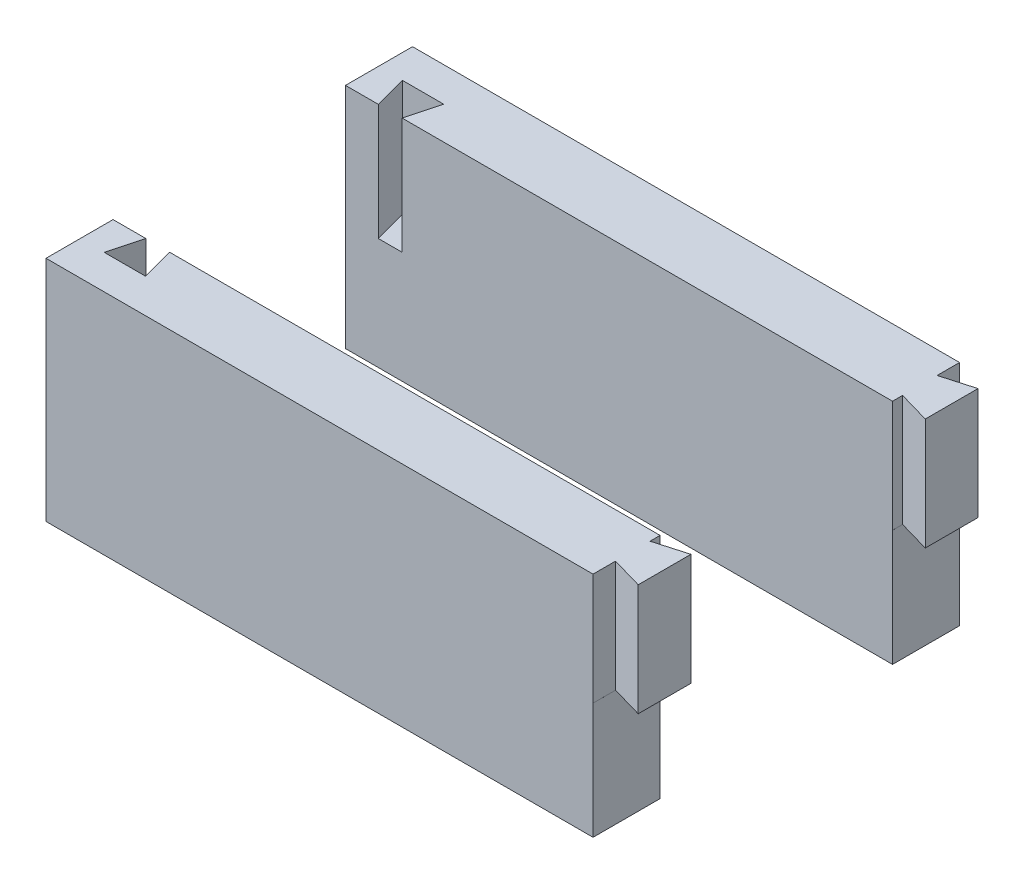
from build123d import *

# Parameters (mm, degrees)
SKETCH1_W               = 129.5
SKETCH1_H               = 51
BOSS_EXTRUDE1_DEPTH     = 15
CUT_EXTRUDE2_DEPTH      = 1
CUT_EXTRUDE2_DEPTH_BACK = 26
CUT_EXTRUDE4_DEPTH      = 25
SKETCH7_W               = 7.11
SKETCH7_H               = 15
CUT_EXTRUDE5_DEPTH      = 26


with BuildPart() as part:
    # Sketch1 → Boss-Extrude1 (new body)
    with BuildSketch(Plane.XY):
        with Locations((3.813380282, 3.112676056)):
            Rectangle(SKETCH1_W, SKETCH1_H)
    extrude(amount=BOSS_EXTRUDE1_DEPTH)

    # Sketch3 → Cut-Extrude2 (cut, two sides)
    with BuildSketch(Plane(origin=(0, 28.612676056, 0), x_dir=(1, 0, 0), z_dir=(0, 1, 0))) as cut_extrude2_sk:
        Polygon((-331.668282544, 0), (-60.936619718, 0), (-53.586619718, 0), (-55.553644461, -7.34103628), (-46.319594976, -7.34103628), (-48.286619718, 0), (-118.35713017, 261.506705118), (-537.936404333, 603.757732463), (-751.247556708, 342.251027345), align=None)
    extrude(amount=CUT_EXTRUDE2_DEPTH, mode=Mode.SUBTRACT)
    extrude(cut_extrude2_sk.sketch, amount=-CUT_EXTRUDE2_DEPTH_BACK, mode=Mode.SUBTRACT)

    # Sketch5 → Cut-Extrude4 (cut)
    with BuildSketch(Plane(origin=(0, 28.612676056, 0), x_dir=(1, 0, 0), z_dir=(0, 1, 0))):
        Polygon((61.450043732, 0), (68.563380282, 0), (68.563380282, -0.210283567), (61.450043732, -2.25), align=None)
        Polygon((61.450043732, -15), (61.450043732, -9.970567134), (68.563380282, -12.010283567), (68.563380282, -15), align=None)
    extrude(amount=-CUT_EXTRUDE4_DEPTH, mode=Mode.SUBTRACT)

    # Sketch7 → Cut-Extrude5 (cut)
    with BuildSketch(Plane.XZ.offset(22.387323944)):
        with Locations((65.008380282, 7.5)):
            Rectangle(SKETCH7_W, SKETCH7_H)
    extrude(amount=-CUT_EXTRUDE5_DEPTH, mode=Mode.SUBTRACT)


with BuildPart() as body_2:
    # Mirror2: mirrored copy
    add(part.part.mirror(Plane(origin=(0, 0, -26), x_dir=(1, 0, 0), z_dir=(0, 0, -1))))


solid = Compound([part.part, body_2.part])
